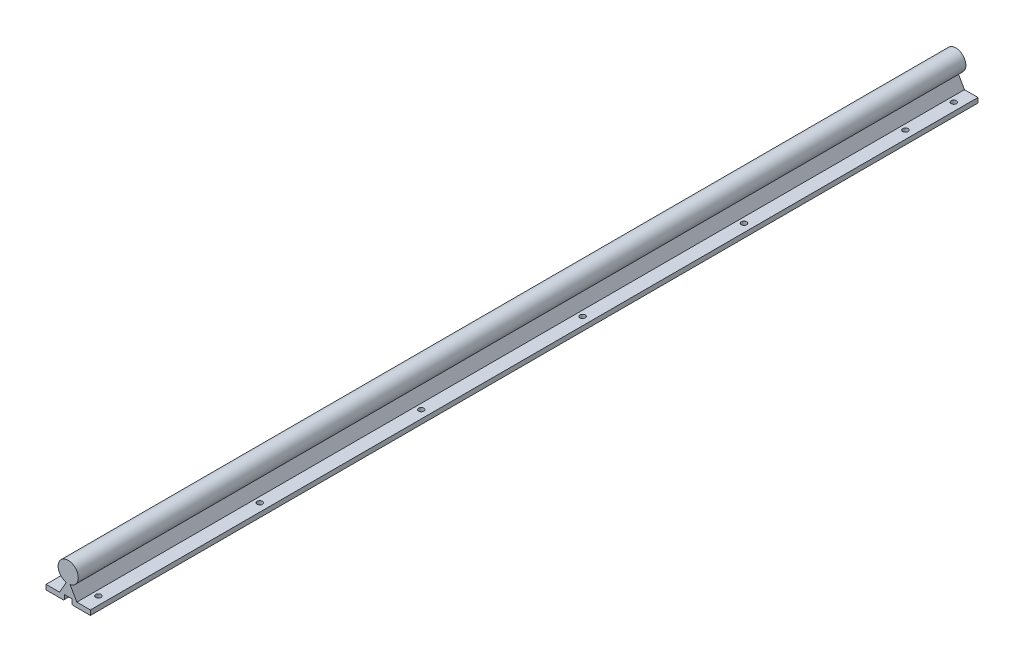
from build123d import *

# Parameters (mm, degrees)
SKETCH1_R               = 12.5
BOSS_EXTRUDE1_DEPTH     = 1100
CHAMFER1_SIZE           = 1
SKETCH2_R               = 3.3
CUT_EXTRUDE1_DEPTH      = 40.5
CUT_EXTRUDE1_DEPTH_BACK = 7


with BuildPart() as part:
    # Sketch1 → Boss-Extrude1 (new body)
    with BuildSketch(Plane.XY):
        with Locations((0, 33)):
            Circle(SKETCH1_R)
        Polygon((-27.5, 0), (-4.75, 0), (-4.75, 6.5), (4.75, 6.5), (4.75, 0), (27.5, 0), (27.5, 6), (10.75, 6), (2.089745962, 21), (-2.089745962, 21), (-10.75, 6), (-27.5, 6), align=None)
    extrude(amount=-BOSS_EXTRUDE1_DEPTH)

    # Chamfer1
    chamfer1_edges = [part.edges().sort_by_distance(p)[0] for p in [
        (4.75, 0, -550),
        (-4.75, 0, -550),
    ]]
    chamfer(chamfer1_edges, length=CHAMFER1_SIZE)

    # Sketch2 → Cut-Extrude1 (cut, two sides)
    with BuildSketch(Plane(origin=(0, 6, 0), x_dir=(1, 0, 0), z_dir=(0, 1, 0))) as cut_extrude1_sk:
        with Locations((17.5, 20)):
            Circle(SKETCH2_R)
        with Locations((-17.5, 20)):
            Circle(SKETCH2_R)
        with Locations((-17.5, 220)):
            Circle(SKETCH2_R)
        with Locations((17.5, 220)):
            Circle(SKETCH2_R)
        with Locations((-17.5, 420)):
            Circle(SKETCH2_R)
        with Locations((17.5, 420)):
            Circle(SKETCH2_R)
        with Locations((-17.5, 620)):
            Circle(SKETCH2_R)
        with Locations((17.5, 620)):
            Circle(SKETCH2_R)
        with Locations((-17.5, 820)):
            Circle(SKETCH2_R)
        with Locations((17.5, 820)):
            Circle(SKETCH2_R)
        with Locations((-17.5, 1020)):
            Circle(SKETCH2_R)
        with Locations((17.5, 1020)):
            Circle(SKETCH2_R)
        with Locations((-17.5, 1220)):
            Circle(SKETCH2_R)
        with Locations((17.5, 1220)):
            Circle(SKETCH2_R)
        with Locations((-17.5, 1420)):
            Circle(SKETCH2_R)
        with Locations((17.5, 1420)):
            Circle(SKETCH2_R)
        with Locations((-17.5, 1620)):
            Circle(SKETCH2_R)
        with Locations((17.5, 1620)):
            Circle(SKETCH2_R)
        with Locations((17.5, 1080)):
            Circle(SKETCH2_R)
        with Locations((-17.5, 1080)):
            Circle(SKETCH2_R)
    extrude(amount=CUT_EXTRUDE1_DEPTH, mode=Mode.SUBTRACT)
    extrude(cut_extrude1_sk.sketch, amount=-CUT_EXTRUDE1_DEPTH_BACK, mode=Mode.SUBTRACT)


solid = part.part
